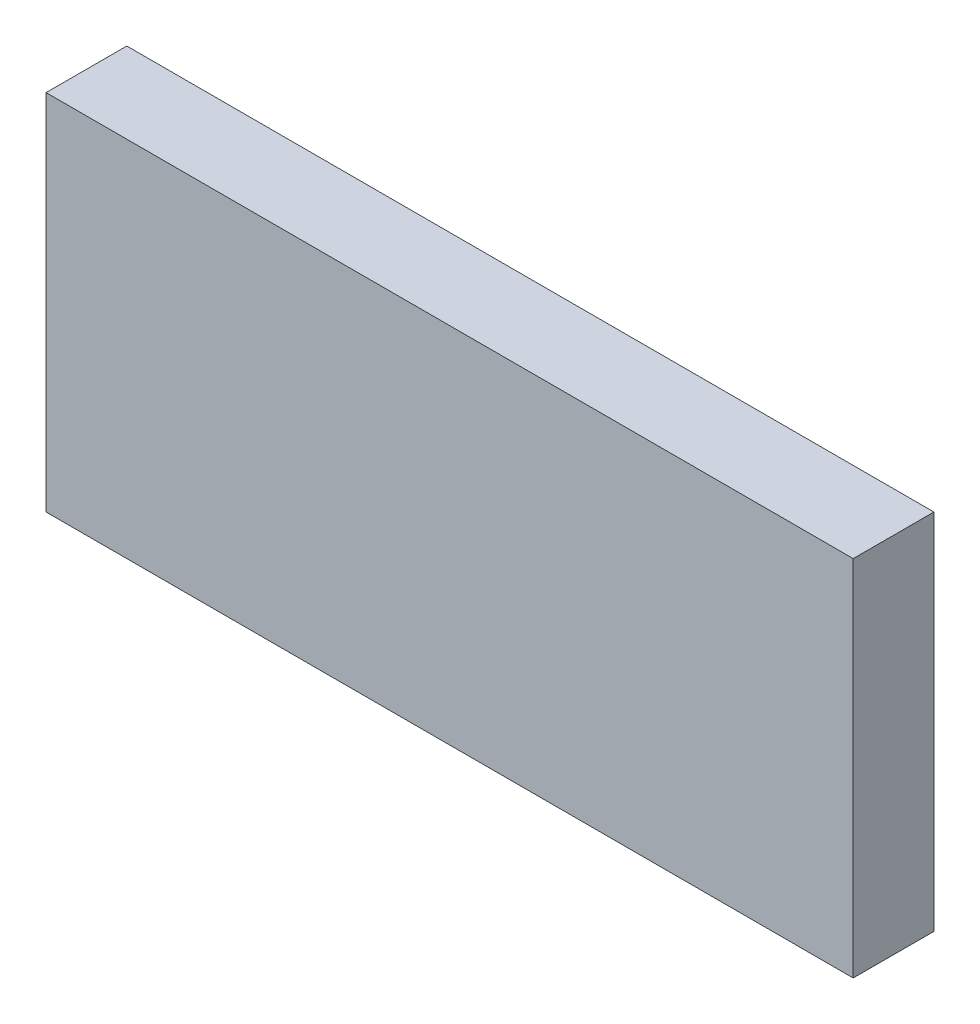
from build123d import *

# Parameters (mm, degrees)
SKETCH3_W           = 40
SKETCH3_H           = 18
BOSS_EXTRUDE1_DEPTH = 4


with BuildPart() as part:
    # Sketch3 → Boss-Extrude1 (new body)
    with BuildSketch(Plane.XY):
        with Locations((-39.707042292, 20.440909091)):
            Rectangle(SKETCH3_W, SKETCH3_H)
    extrude(amount=BOSS_EXTRUDE1_DEPTH)


solid = part.part
